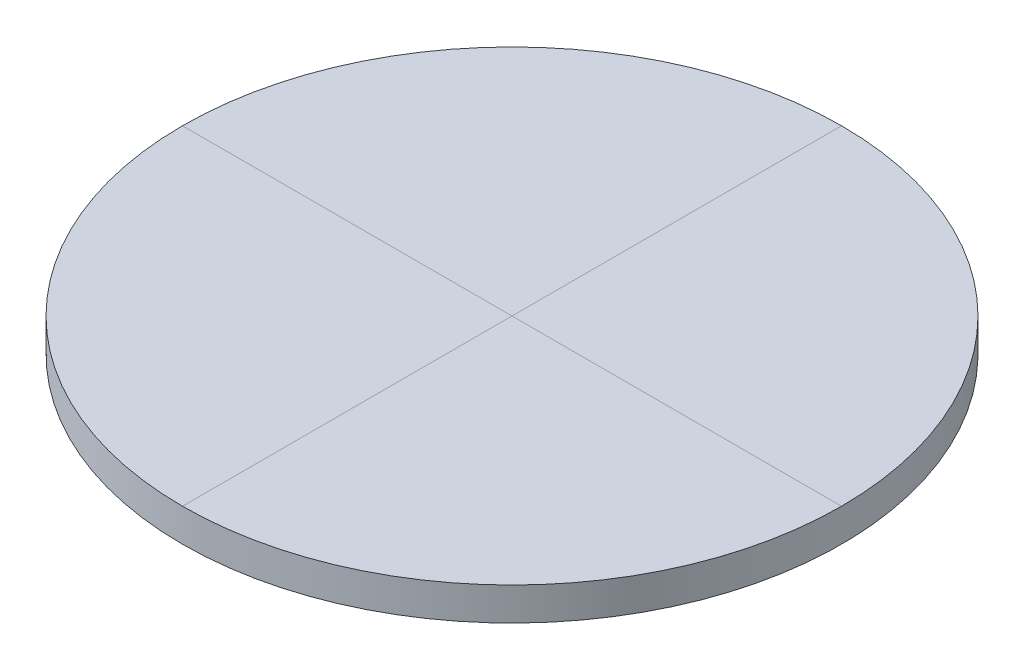
from build123d import *

# Parameters (mm, degrees)
SKETCH1_R           = 30
BOSS_EXTRUDE1_DEPTH = 3


with BuildPart() as part:
    # Sketch1 → Boss-Extrude1 (new body)
    with BuildSketch(Plane(origin=(0, 0, 0), x_dir=(1, 0, 0), z_dir=(0, 1, 0))):
        Circle(SKETCH1_R)
    extrude(amount=BOSS_EXTRUDE1_DEPTH)


solid = part.part
